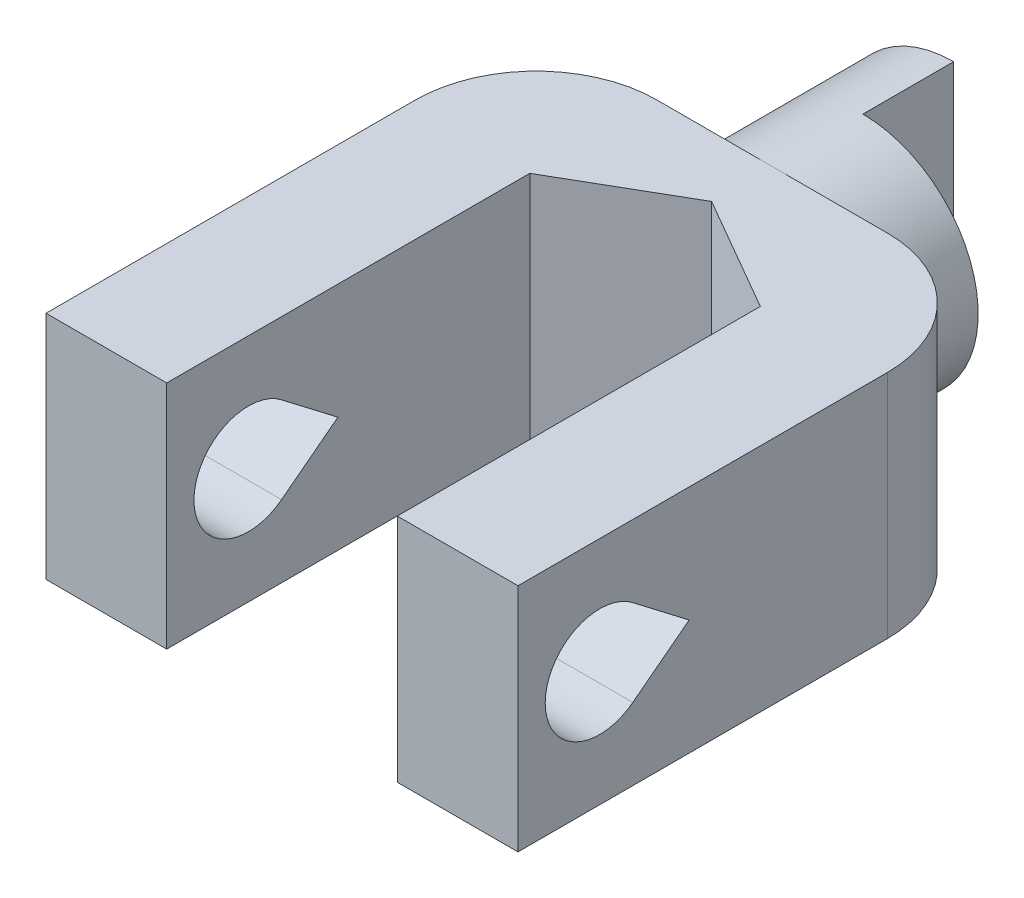
from build123d import *

# Parameters (mm, degrees)
CROQUIS1_R                        = 3.175
SALIENTE_EXTRUIR1_DEPTH           = 5
CROQUIS2_W                        = 13
CROQUIS2_H                        = 6.35
SALIENTE_EXTRUIR2_DEPTH           = 13.5
CORTAR_EXTRUIR2_REACH             = 5.175
CROQUIS5_W                        = 3.175
CROQUIS5_H                        = 2.5
CORTAR_EXTRUIR2_DIRECTION_2_REACH = 5.175
CORTAR_EXTRUIR6_REACH             = 8.35
CORTAR_EXTRUIR7_DEPTH             = 6.35
CORTAR_EXTRUIR8_DEPTH             = 13


with BuildPart() as part:
    # Croquis1 → Saliente-Extruir1 (new body)
    with BuildSketch(Plane.XY):
        Circle(CROQUIS1_R)
    extrude(amount=SALIENTE_EXTRUIR1_DEPTH)

    # Croquis2 → Saliente-Extruir2 (add)
    with BuildSketch(Plane.XY.offset(5)):
        Rectangle(CROQUIS2_W, CROQUIS2_H)
    extrude(amount=SALIENTE_EXTRUIR2_DEPTH)

    # Croquis5 → Cortar-Extruir2 (cut, up to next)
    with BuildSketch(Plane(origin=(0, 0, 0), x_dir=(1, 0, 0), z_dir=(0, 1, 0)), mode=Mode.PRIVATE) as cortar_extruir2_sk1:
        with Locations((1.5875, -1.25)):
            Rectangle(CROQUIS5_W, CROQUIS5_H)
    cortar_extruir2_tool1 = extrude(cortar_extruir2_sk1.sketch, amount=-CORTAR_EXTRUIR2_REACH, mode=Mode.PRIVATE) & part.part
    add(cortar_extruir2_tool1.solids().sort_by_distance((1.5875, 0, 1.25))[0], mode=Mode.SUBTRACT)

    # Croquis5 → Cortar-Extruir2 direction 2 (cut, up to next)
    with BuildSketch(Plane(origin=(0, 0, 0), x_dir=(1, 0, 0), z_dir=(0, 1, 0)), mode=Mode.PRIVATE) as cortar_extruir2_direction_2_sk1:
        with Locations((1.5875, -1.25)):
            Rectangle(CROQUIS5_W, CROQUIS5_H)
    cortar_extruir2_direction_2_tool1 = extrude(cortar_extruir2_direction_2_sk1.sketch, amount=CORTAR_EXTRUIR2_DIRECTION_2_REACH, mode=Mode.PRIVATE) & part.part
    add(cortar_extruir2_direction_2_tool1.solids().sort_by_distance((1.5875, 0, 1.25))[0], mode=Mode.SUBTRACT)

    # Croquis7 → Cortar-Extruir6 (cut, up to next)
    with BuildSketch(Plane(origin=(0, 3.175, 0), x_dir=(1, 0, 0), z_dir=(0, 1, 0)), mode=Mode.PRIVATE) as cortar_extruir6_sk1:
        Polygon((-3.175, -18.5), (3.175, -18.5), (3.175, -8.5), (0, -6.666912895), (-3.175, -8.5), align=None)
    cortar_extruir6_tool1 = extrude(cortar_extruir6_sk1.sketch, amount=-CORTAR_EXTRUIR6_REACH, mode=Mode.PRIVATE) & part.part
    add(cortar_extruir6_tool1.solids().sort_by_distance((0, 3.175, 13.028903))[0], mode=Mode.SUBTRACT)

    # Croquis8 → Cortar-Extruir7 (cut)
    with BuildSketch(Plane(origin=(0, 3.175, 0), x_dir=(1, 0, 0), z_dir=(0, 1, 0))):
        with BuildLine():
            Line((-6.5, -5), (-3.175, -5))
            ThreePointArc((-3.175, -5), (-5.526130047, -5.973869953), (-6.5, -8.325))
            Line((-6.5, -8.325), (-6.5, -5))
        make_face()
    cortar_extruir7 = extrude(amount=-CORTAR_EXTRUIR7_DEPTH, mode=Mode.SUBTRACT)

    # Simetría1: Cortar-Extruir7 across plane
    add(cortar_extruir7.mirror(Plane(origin=(0, 0, 0), x_dir=(0, 0, 1), z_dir=(1, 0, 0))), mode=Mode.SUBTRACT)

    # Croquis9 → Cortar-Extruir8 (cut)
    with BuildSketch(Plane(origin=(6.5, 0, 0), x_dir=(0, 0, -1), z_dir=(1, 0, 0))):
        with BuildLine():
            Line((-15.336857856, 1.19003001), (-13.785980552, 0))
            Line((-13.785980552, 0), (-15.336857856, -1.19003001))
            ThreePointArc((-15.336857856, -1.19003001), (-17.75, 0), (-15.336857856, 1.19003001))
        make_face()
    extrude(amount=-CORTAR_EXTRUIR8_DEPTH, mode=Mode.SUBTRACT)


solid = part.part
